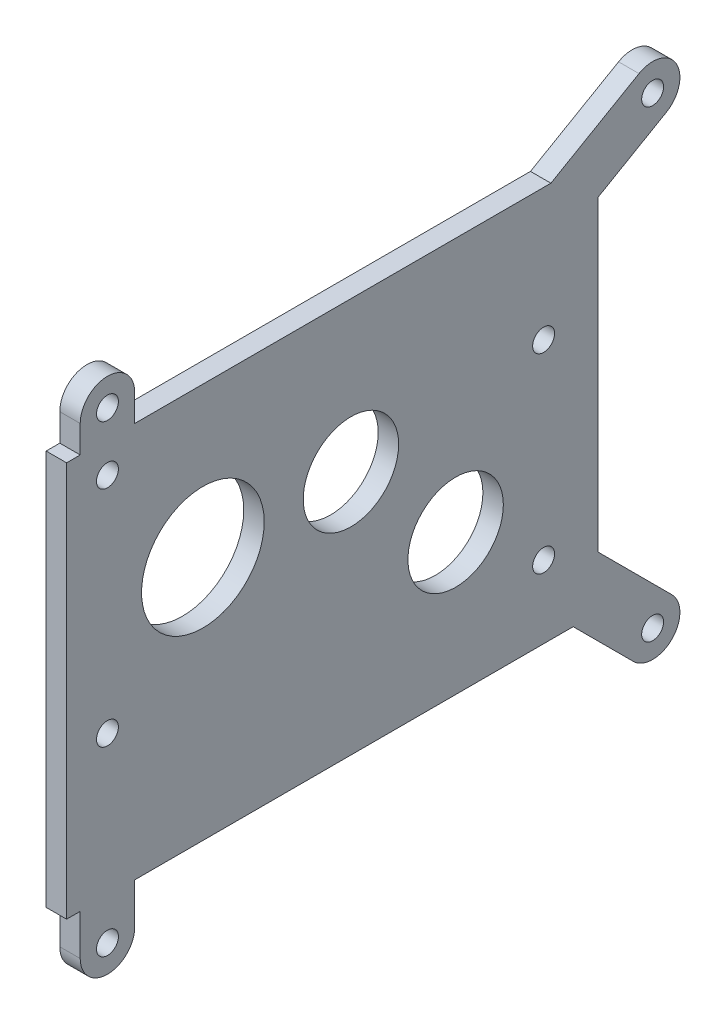
from build123d import *

# Parameters (mm, degrees)
SKETCH1_W              = 123.825
SKETCH1_H              = 92.075
BOSS_EXTRUDE2_DEPTH    = 4.7625
SKETCH2_R              = 11.1125
SKETCH2_R_2            = 14.2875
CUT_EXTRUDE1_DEPTH     = 5.7625
F_10_CLEARANCE_HOLE1_D = 5.1054
SKETCH8_R              = 14.2875
CUT_EXTRUDE3_DEPTH     = 5.7625
SKETCH9_R              = 14.2875
SKETCH9_R_2            = 11.1125
BOSS_EXTRUDE3_DEPTH    = 4.7625
BOSS_EXTRUDE4_DEPTH    = 4.7625
F_10_CLEARANCE_HOLE2_D = 5.1054


with BuildPart() as part:
    # Sketch1 → Boss-Extrude2 (new body)
    with BuildSketch(Plane(origin=(0, 0, 0), x_dir=(0, 0, -1), z_dir=(1, 0, 0))):
        with Locations((61.9125, 46.0375)):
            Rectangle(SKETCH1_W, SKETCH1_H)
    extrude(amount=BOSS_EXTRUDE2_DEPTH)

    # Sketch2 → Cut-Extrude1 (cut, through all)
    with BuildSketch(Plane(origin=(4.7625, 0, 0), x_dir=(0, 0, -1), z_dir=(1, 0, 0))):
        with Locations((66.2432, 57.15)):
            Circle(SKETCH2_R)
        with Locations((31.75, 57.15)):
            Circle(SKETCH2_R)
        with Locations((90.633575625, 32.759624375)):
            Circle(SKETCH2_R_2)
    extrude(amount=-CUT_EXTRUDE1_DEPTH, mode=Mode.SUBTRACT)

    # #10 Clearance Hole1 (through all)
    with Locations(Plane(origin=(4.7625, 0, 0), x_dir=(0, 0, -1), z_dir=(1, 0, 0))):
        with Locations((9.525, 84.829624375), (111.125, 61.334624375), (9.525, 32.759624375), (111.125, 16.884624375)):
            Hole(F_10_CLEARANCE_HOLE1_D / 2)

    # Sketch8 → Cut-Extrude3 (cut, through all)
    with BuildSketch(Plane(origin=(4.7625, 0, 0), x_dir=(0, 0, -1), z_dir=(1, 0, 0))):
        with Locations((31.75, 57.15)):
            Circle(SKETCH8_R)
    extrude(amount=-CUT_EXTRUDE3_DEPTH, mode=Mode.SUBTRACT)

    # Sketch9 → Boss-Extrude3 (add)
    with BuildSketch(Plane(origin=(4.7625, 0, 0), x_dir=(0, 0, -1), z_dir=(1, 0, 0))):
        with Locations((90.633575625, 32.759624375)):
            Circle(SKETCH9_R)
        with Locations((90.633575625, 32.759624375)):
            Circle(SKETCH9_R_2, mode=Mode.SUBTRACT)
    extrude(amount=-BOSS_EXTRUDE3_DEPTH)

    # Sketch11 → Boss-Extrude4 (add)
    with BuildSketch(Plane.ZY):
        with BuildLine():
            Line((-132.034871939, -14.015128061), (-118.019743879, 0))
            Line((-118.019743879, 0), (-123.825, 0))
            Line((-123.825, 0), (-123.825, 12.155256121))
            Line((-123.825, 12.155256121), (-141.015128061, -5.034871939))
            ThreePointArc((-141.015128061, -5.034871939), (-141.015128061, -14.015128061), (-132.034871939, -14.015128061))
        make_face()
        with BuildLine():
            Line((-139.7, 92.925738686), (-123.825, 83.760303163))
            Line((-123.825, 83.760303163), (-123.825, 92.075))
            Line((-123.825, 92.075), (-112.826477372, 92.075))
            Line((-112.826477372, 92.075), (-133.35, 103.924261314))
            ThreePointArc((-133.35, 103.924261314), (-142.024261314, 101.6), (-139.7, 92.925738686))
        make_face()
        with BuildLine():
            Line((-15.875, -9.525), (-15.875, 0))
            Line((-15.875, 0), (-3.175, 0))
            Line((-3.175, 0), (-3.175, -9.525))
            ThreePointArc((-3.175, -9.525), (-9.525, -15.875), (-15.875, -9.525))
        make_face()
        with BuildLine():
            Line((-15.875, 98.425), (-15.875, 92.075))
            Line((-15.875, 92.075), (-3.175, 92.075))
            Line((-3.175, 92.075), (-3.175, 98.425))
            ThreePointArc((-3.175, 98.425), (-9.525, 104.775), (-15.875, 98.425))
        make_face()
    extrude(amount=-BOSS_EXTRUDE4_DEPTH)

    # #10 Clearance Hole2 (through all)
    with Locations(Plane.ZY):
        with Locations((-136.525, -9.525), (-136.525, 98.425), (-9.525, 98.425), (-9.525, -9.525)):
            Hole(F_10_CLEARANCE_HOLE2_D / 2)


solid = part.part
